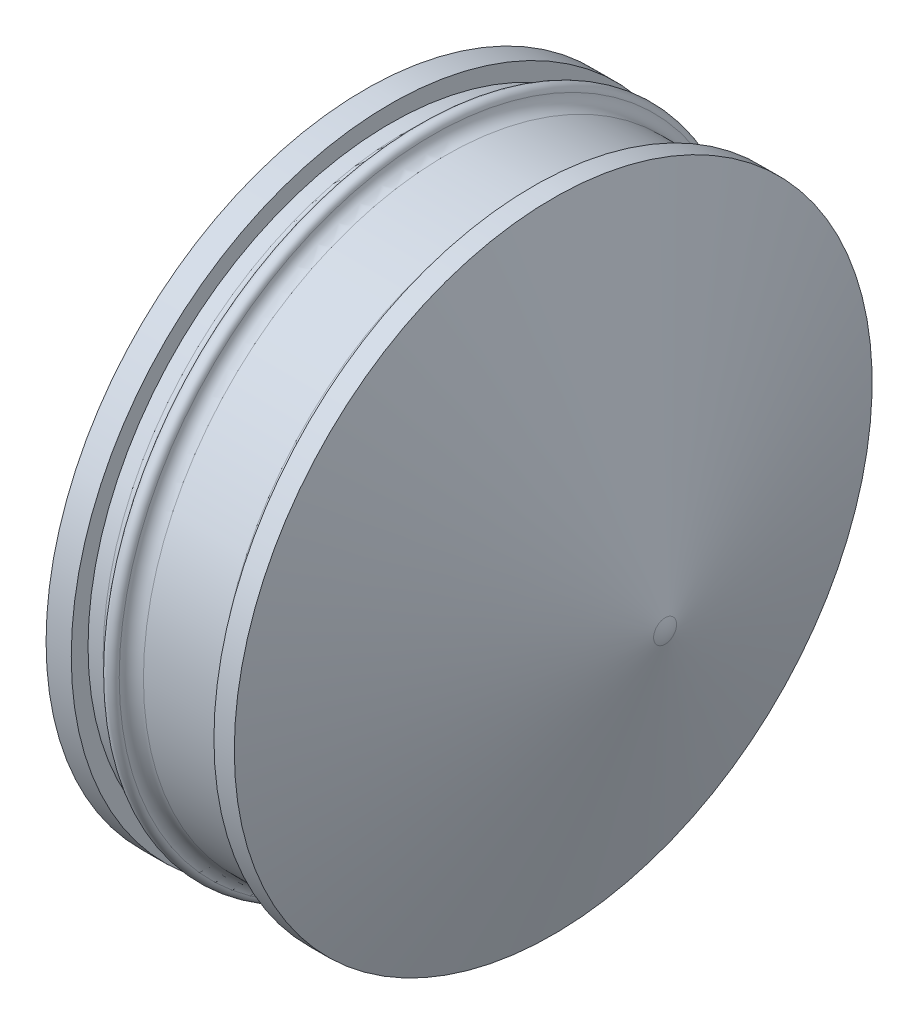
from build123d import *


with BuildPart() as part:
    # Sketch1 → Revolve: OD (revolve)
    with BuildSketch(Plane.XY):
        with BuildLine():
            Line((0, 12.065), (0.9525, 12.065))
            Line((0.9525, 12.065), (0.9525, 11.43))
            Line((0.9525, 11.43), (1.524, 11.43))
            ThreePointArc((1.524, 11.43), (1.849213675, 11.54774359), (2.023672131, 11.846393443))
            ThreePointArc((2.023672131, 11.846393443), (2.286, 12.065), (2.548327869, 11.846393443))
            ThreePointArc((2.548327869, 11.846393443), (2.722786325, 11.54774359), (3.048, 11.43))
            Line((3.048, 11.43), (5.842, 11.43))
            ThreePointArc((5.842, 11.43), (6.201210245, 11.578789755), (6.35, 11.938))
            Line((6.35, 11.938), (6.35, 12.065))
            Line((6.35, 12.065), (7.120204895, 12.065))
            Line((7.120204895, 12.065), (11.353409628, 0.434365582))
            ThreePointArc((11.353409628, 0.434365582), (11.410705846, 0.220533186), (11.43, 0))
            Line((11.43, 0), (0, 0))
            Line((0, 0), (0, 12.065))
        make_face()
    revolve(axis=Axis((-0.699583002, 0, 0), (1, 0, 0)))

    # Sketch3 → Cut-Revolve: ID (revolve, cut)
    with BuildSketch(Plane.XY):
        Polygon((0, 0), (0, 7.62), (2.0955, 7.62), (2.0955, 11.303), (5.775743288, 11.303), (9.889698846, 0), align=None)
    revolve(axis=Axis((-1.469925142, 0, 0), (1, 0, 0)), mode=Mode.SUBTRACT)


solid = part.part
